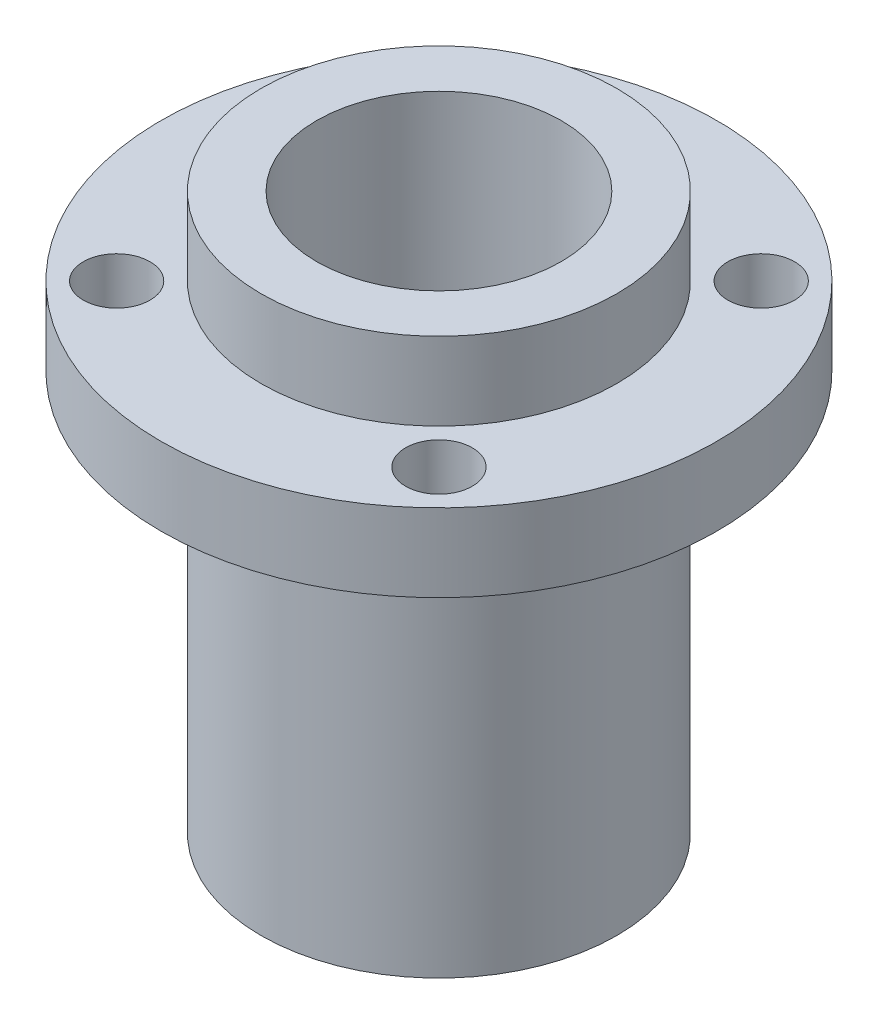
from build123d import *

# Parameters (mm, degrees)
SKETCH1_R           = 12.5
BOSS_EXTRUDE1_DEPTH = 3.5
BOSS_EXTRUDE2_START = 3.5
SKETCH2_R           = 8
SKETCH2_R_2         = 5.5
BOSS_EXTRUDE2_DEPTH = 3.5
SKETCH2_2_R         = 8
SKETCH2_2_R_2       = 5.5
BOSS_EXTRUDE3_DEPTH = 18
SKETCH3_R           = 5.5
CUT_EXTRUDE1_DEPTH  = 8
BOSS_EXTRUDE4_START = -18
SKETCH4_R           = 5.5
SKETCH4_R_2         = 2.05
BOSS_EXTRUDE4_DEPTH = 2.5
SKETCH5_R           = 1.5
CUT_EXTRUDE2_DEPTH  = 8


with BuildPart() as part:
    # Sketch1 → Boss-Extrude1 (new body)
    with BuildSketch(Plane(origin=(0, 0, 0), x_dir=(1, 0, 0), z_dir=(0, 1, 0))):
        Circle(SKETCH1_R)
    extrude(amount=BOSS_EXTRUDE1_DEPTH)

    # Sketch2 → Boss-Extrude2 (add)
    with BuildSketch(Plane(origin=(0, 0, 0), x_dir=(1, 0, 0), z_dir=(0, 1, 0)).offset(BOSS_EXTRUDE2_START)):
        Circle(SKETCH2_R)
        Circle(SKETCH2_R_2, mode=Mode.SUBTRACT)
    extrude(amount=BOSS_EXTRUDE2_DEPTH)

    # Sketch2_2 → Boss-Extrude3 (add)
    with BuildSketch(Plane(origin=(0, 0, 0), x_dir=(1, 0, 0), z_dir=(0, 1, 0))):
        Circle(SKETCH2_2_R)
        Circle(SKETCH2_2_R_2, mode=Mode.SUBTRACT)
    extrude(amount=-BOSS_EXTRUDE3_DEPTH)

    # Sketch3 → Cut-Extrude1 (cut, through all)
    with BuildSketch(Plane(origin=(0, 0, 0), x_dir=(1, 0, 0), z_dir=(0, 1, 0))):
        Circle(SKETCH3_R)
    extrude(amount=CUT_EXTRUDE1_DEPTH, mode=Mode.SUBTRACT)

    # Sketch4 → Boss-Extrude4 (add)
    with BuildSketch(Plane(origin=(0, 0, 0), x_dir=(1, 0, 0), z_dir=(0, 1, 0)).offset(BOSS_EXTRUDE4_START)):
        Circle(SKETCH4_R)
        Circle(SKETCH4_R_2, mode=Mode.SUBTRACT)
    extrude(amount=BOSS_EXTRUDE4_DEPTH)

    # Sketch5 → Cut-Extrude2 (cut, through all)
    with BuildSketch(Plane(origin=(0, 0, 0), x_dir=(1, 0, 0), z_dir=(0, 1, 0))):
        with Locations((-7.247844507, 7.247844507)):
            Circle(SKETCH5_R)
        with Locations((7.247844507, 7.247844507)):
            Circle(SKETCH5_R)
        with Locations((7.247844507, -7.247844507)):
            Circle(SKETCH5_R)
        with Locations((-7.247844507, -7.247844507)):
            Circle(SKETCH5_R)
    extrude(amount=CUT_EXTRUDE2_DEPTH, mode=Mode.SUBTRACT)


solid = part.part
